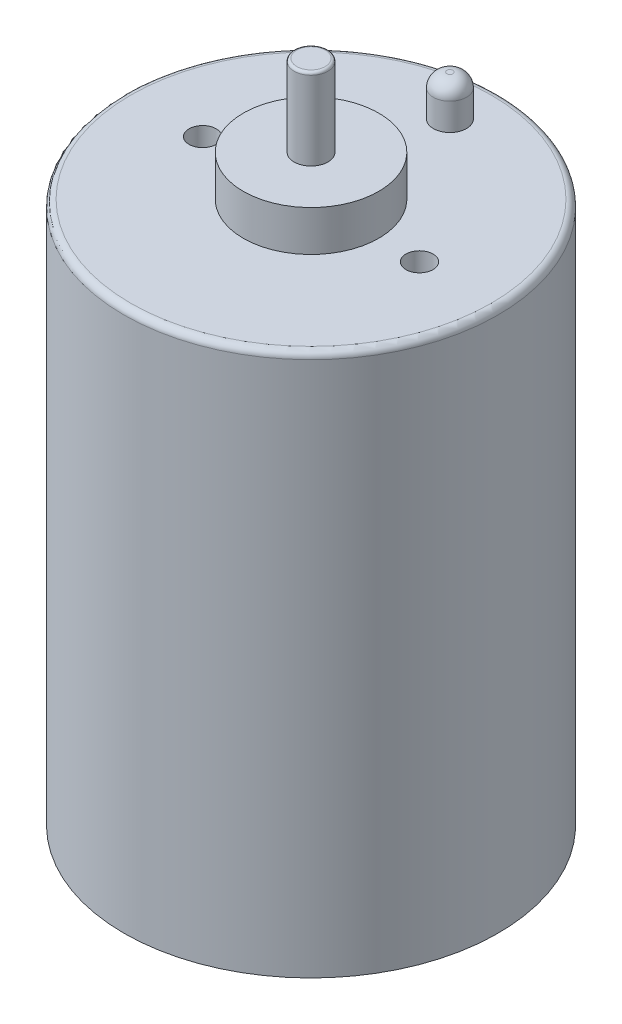
from build123d import *

# Parameters (mm, degrees)
SKETCH1_R           = 13.8
BOSS_EXTRUDE1_DEPTH = 40
SKETCH2_R           = 5
BOSS_EXTRUDE2_DEPTH = 3
SKETCH3_R           = 1
CUT_EXTRUDE1_DEPTH  = 3
SKETCH4_R           = 1.225
BOSS_EXTRUDE3_DEPTH = 3
FILLET1_R           = 1
FILLET2_R           = 0.5
SKETCH5_R           = 1.25
BOSS_EXTRUDE4_DEPTH = 6
FILLET3_R           = 0.2


with BuildPart() as part:
    # Sketch1 → Boss-Extrude1 (new body)
    with BuildSketch(Plane(origin=(0, 0, 0), x_dir=(1, 0, 0), z_dir=(0, 1, 0))):
        Circle(SKETCH1_R)
    extrude(amount=BOSS_EXTRUDE1_DEPTH)

    # Sketch2 → Boss-Extrude2 (add)
    with BuildSketch(Plane(origin=(0, 40, 0), x_dir=(1, 0, 0), z_dir=(0, 1, 0))):
        Circle(SKETCH2_R)
    extrude(amount=BOSS_EXTRUDE2_DEPTH)

    # Sketch3 → Cut-Extrude1 (cut)
    with BuildSketch(Plane(origin=(0, 40, 0), x_dir=(1, 0, 0), z_dir=(0, 1, 0))):
        with Locations((-8, 0)):
            Circle(SKETCH3_R)
        with Locations((8, 0)):
            Circle(SKETCH3_R)
    extrude(amount=-CUT_EXTRUDE1_DEPTH, mode=Mode.SUBTRACT)

    # Sketch4 → Boss-Extrude3 (add)
    with BuildSketch(Plane(origin=(0, 40, 0), x_dir=(1, 0, 0), z_dir=(0, 1, 0))):
        with Locations((0, 10.246950766)):
            Circle(SKETCH4_R)
    extrude(amount=BOSS_EXTRUDE3_DEPTH)

    # Fillet1
    fillet1_edges = [part.edges().sort_by_distance(p)[0] for p in [
        (-1.225, 43, -10.246950766),
    ]]
    fillet(fillet1_edges, radius=FILLET1_R)

    # Fillet2
    fillet2_edges = [part.edges().sort_by_distance(p)[0] for p in [
        (-13.8, 40, 0),
    ]]
    fillet(fillet2_edges, radius=FILLET2_R)

    # Sketch5 → Boss-Extrude4 (add)
    with BuildSketch(Plane(origin=(0, 43, 0), x_dir=(1, 0, 0), z_dir=(0, 1, 0))):
        Circle(SKETCH5_R)
    extrude(amount=BOSS_EXTRUDE4_DEPTH)

    # Fillet3
    fillet3_edges = [part.edges().sort_by_distance(p)[0] for p in [
        (-1.25, 49, 0),
    ]]
    fillet(fillet3_edges, radius=FILLET3_R)


solid = part.part
